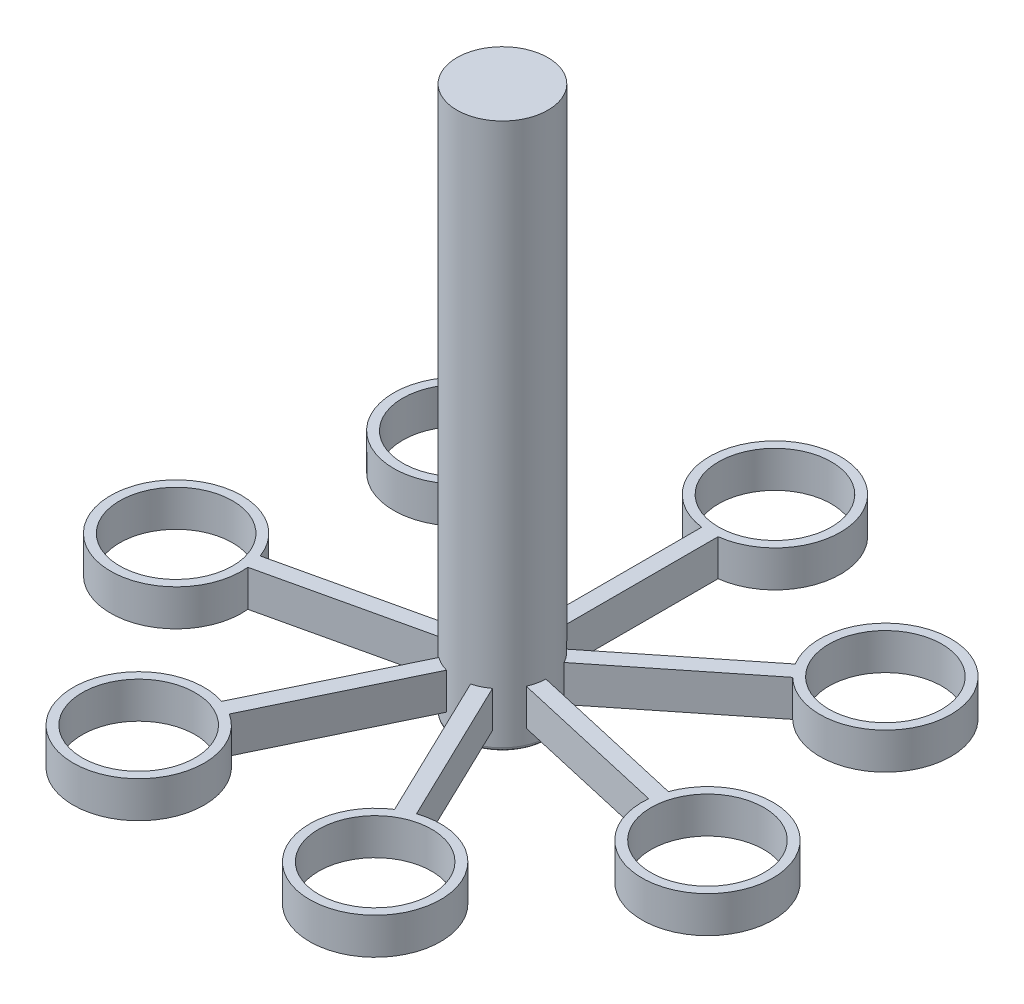
from build123d import *

# Parameters (mm, degrees)
SKETCH1_R           = 12.5
BOSS_EXTRUDE1_DEPTH = 150
BOSS_EXTRUDE2_START = 5
SKETCH3_R           = 15.5
BOSS_EXTRUDE2_DEPTH = 10
CIRPATTERN1_COUNT   = 7
FILLET1_R           = 1


with BuildPart() as part:
    # Sketch1 → Boss-Extrude1 (new body)
    with BuildSketch(Plane(origin=(0, 0, 0), x_dir=(1, 0, 0), z_dir=(0, 1, 0))):
        Circle(SKETCH1_R)
    extrude(amount=BOSS_EXTRUDE1_DEPTH)

    # Sketch3 → Boss-Extrude2 (add)
    with BuildSketch(Plane(origin=(0, 0, 0), x_dir=(1, 0, 0), z_dir=(0, 1, 0)).offset(BOSS_EXTRUDE2_START)):
        with BuildLine():
            Line((-2.253835774, 56.947383215), (-2.253835774, 12.295130105))
            Line((-2.253835774, 12.295130105), (2.253835774, 12.295130105))
            Line((2.253835774, 12.295130105), (2.253835774, 56.947383215))
            ThreePointArc((2.253835774, 56.947383215), (0, 92.805720885), (-2.253835774, 56.947383215))
        make_face()
        with Locations((0, 74.805720885)):
            Circle(SKETCH3_R, mode=Mode.SUBTRACT)
    boss_extrude2 = extrude(amount=BOSS_EXTRUDE2_DEPTH)

    # CirPattern1: Boss-Extrude2 ×7 about axis
    cirpattern1_axis = Axis((0, 0, 0), (0, 1, 0))
    for i in range(1, CIRPATTERN1_COUNT):
        add(boss_extrude2.rotate(cirpattern1_axis, i * 360 / CIRPATTERN1_COUNT))

    # Fillet1
    fillet1_edges = [part.edges().sort_by_distance(p)[0] for p in [
        (-12.5, 0, 0),
    ]]
    fillet(fillet1_edges, radius=FILLET1_R)


solid = part.part
